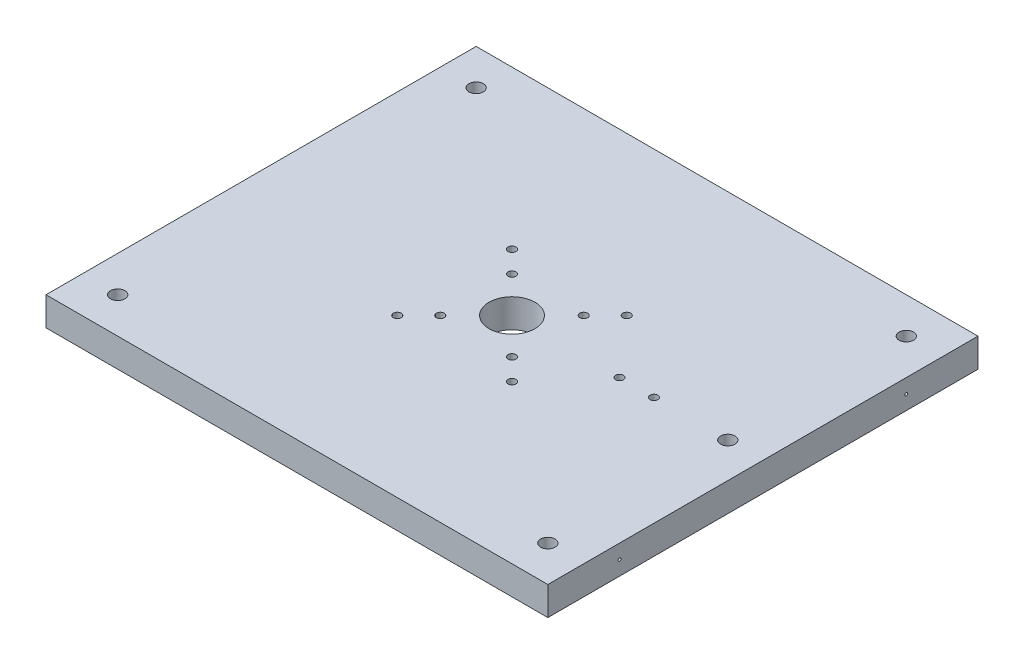
from build123d import *

# Parameters (mm, degrees)
SKETCH1_W           = 350
SKETCH1_H           = 300
BOSS_EXTRUDE1_DEPTH = 20
SKETCH2_R           = 5
CUT_EXTRUDE1_DEPTH  = 21
SKETCH3_R           = 2.75
CUT_EXTRUDE2_DEPTH  = 20
SKETCH4_R           = 5
CUT_EXTRUDE3_DEPTH  = 20
SKETCH5_R           = 2.75
CUT_EXTRUDE4_DEPTH  = 20
SKETCH6_R           = 16
CUT_EXTRUDE5_DEPTH  = 20
SKETCH7_R           = 2.75
CUT_EXTRUDE6_DEPTH  = 20
SKETCH8_R           = 1
CUT_EXTRUDE7_DEPTH  = 15


with BuildPart() as part:
    # Sketch1 → Boss-Extrude1 (new body)
    with BuildSketch(Plane(origin=(0, 0, 0), x_dir=(1, 0, 0), z_dir=(0, 1, 0))):
        Rectangle(SKETCH1_W, SKETCH1_H)
    extrude(amount=BOSS_EXTRUDE1_DEPTH)

    # Sketch2 → Cut-Extrude1 (cut, through all)
    with BuildSketch(Plane(origin=(0, 20, 0), x_dir=(1, 0, 0), z_dir=(0, 1, 0))):
        with Locations((-150, -125)):
            Circle(SKETCH2_R)
        with Locations((-150, 125)):
            Circle(SKETCH2_R)
        with Locations((150, 125)):
            Circle(SKETCH2_R)
        with Locations((150, -125)):
            Circle(SKETCH2_R)
    extrude(amount=-CUT_EXTRUDE1_DEPTH, mode=Mode.SUBTRACT)

    # Sketch3 → Cut-Extrude2 (cut)
    with BuildSketch(Plane(origin=(0, 20, 0), x_dir=(1, 0, 0), z_dir=(0, 1, 0))):
        with Locations((75, 0)):
            Circle(SKETCH3_R)
        with Locations((99, 0)):
            Circle(SKETCH3_R)
    extrude(amount=-CUT_EXTRUDE2_DEPTH, mode=Mode.SUBTRACT)

    # Sketch4 → Cut-Extrude3 (cut)
    with BuildSketch(Plane(origin=(0, 20, 0), x_dir=(1, 0, 0), z_dir=(0, 1, 0))):
        with Locations((150.5, 0)):
            Circle(SKETCH4_R)
    extrude(amount=-CUT_EXTRUDE3_DEPTH, mode=Mode.SUBTRACT)

    # Sketch5 → Cut-Extrude4 (cut)
    with BuildSketch(Plane(origin=(0, 20, 0), x_dir=(1, 0, 0), z_dir=(0, 1, 0))):
        with Locations((-40, 40)):
            Circle(SKETCH5_R)
        with Locations((40, 40)):
            Circle(SKETCH5_R)
        with Locations((40, -40)):
            Circle(SKETCH5_R)
        with Locations((-40, -40)):
            Circle(SKETCH5_R)
    extrude(amount=-CUT_EXTRUDE4_DEPTH, mode=Mode.SUBTRACT)

    # Sketch6 → Cut-Extrude5 (cut)
    with BuildSketch(Plane(origin=(0, 20, 0), x_dir=(1, 0, 0), z_dir=(0, 1, 0))):
        Circle(SKETCH6_R)
    extrude(amount=-CUT_EXTRUDE5_DEPTH, mode=Mode.SUBTRACT)

    # Sketch7 → Cut-Extrude6 (cut)
    with BuildSketch(Plane(origin=(0, 20, 0), x_dir=(1, 0, 0), z_dir=(0, 1, 0))):
        with Locations((-25, 25)):
            Circle(SKETCH7_R)
        with Locations((25, 25)):
            Circle(SKETCH7_R)
        with Locations((25, -25)):
            Circle(SKETCH7_R)
        with Locations((-25, -25)):
            Circle(SKETCH7_R)
    extrude(amount=-CUT_EXTRUDE6_DEPTH, mode=Mode.SUBTRACT)

    # Sketch8 → Cut-Extrude7 (cut)
    with BuildSketch(Plane(origin=(175, 0, 0), x_dir=(0, 0, -1), z_dir=(1, 0, 0))):
        with Locations((-100, 10)):
            Circle(SKETCH8_R)
        with Locations((100, 10)):
            Circle(SKETCH8_R)
    extrude(amount=-CUT_EXTRUDE7_DEPTH, mode=Mode.SUBTRACT)


solid = part.part
